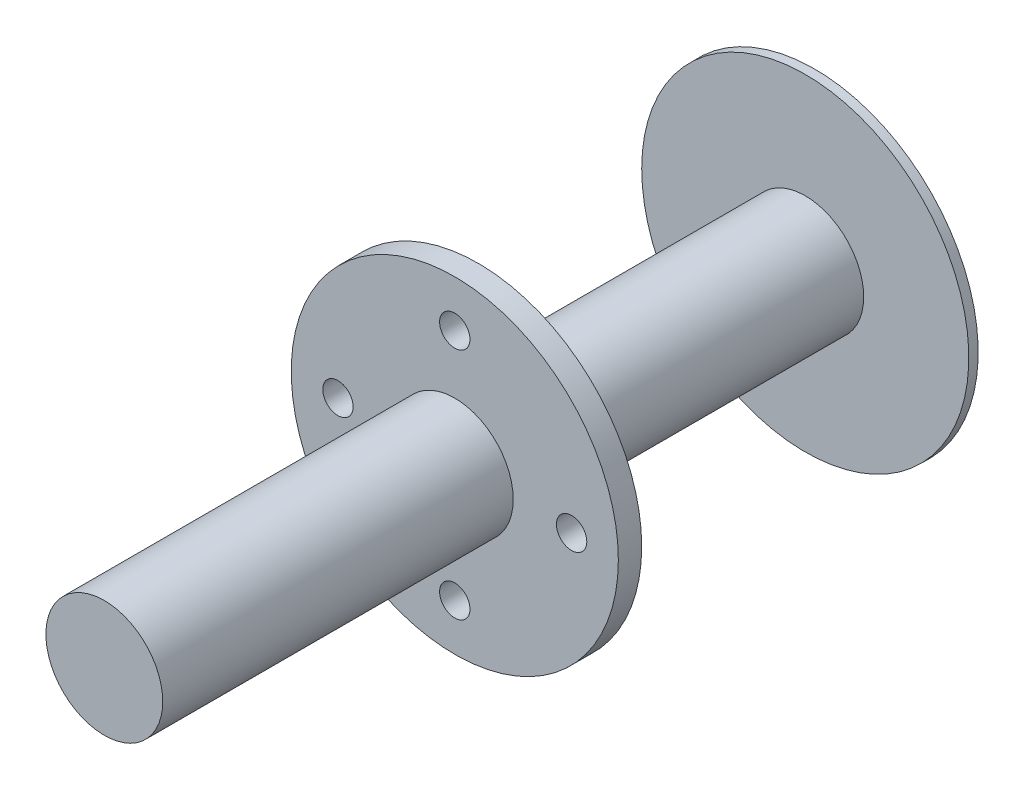
from build123d import *

# Parameters (mm, degrees)
SKETCH1_R                = 70
SKETCH1_R_2              = 6.5
BOSS_EXTRUDE1_DEPTH      = 10
SKETCH2_R                = 25
BOSS_EXTRUDE2_DEPTH      = 150
BOSS_EXTRUDE2_DEPTH_BACK = 150
SKETCH3_R                = 70
BOSS_EXTRUDE3_DEPTH      = 4


with BuildPart() as part:
    # Sketch1 → Boss-Extrude1 (new body)
    with BuildSketch(Plane.XY):
        Circle(SKETCH1_R)
        with Locations((0, 50)):
            Circle(SKETCH1_R_2, mode=Mode.SUBTRACT)
        with Locations((50, 0)):
            Circle(SKETCH1_R_2, mode=Mode.SUBTRACT)
        with Locations((0, -50)):
            Circle(SKETCH1_R_2, mode=Mode.SUBTRACT)
        with Locations((-50, 0)):
            Circle(SKETCH1_R_2, mode=Mode.SUBTRACT)
    extrude(amount=BOSS_EXTRUDE1_DEPTH)

    # Sketch2 → Boss-Extrude2 (add, two sides)
    with BuildSketch(Plane.XY.offset(10)) as boss_extrude2_sk:
        Circle(SKETCH2_R)
    extrude(amount=BOSS_EXTRUDE2_DEPTH)
    extrude(boss_extrude2_sk.sketch, amount=-BOSS_EXTRUDE2_DEPTH_BACK)

    # Sketch3 → Boss-Extrude3 (add)
    with BuildSketch(Plane(origin=(0, 0, -140), x_dir=(-1, 0, 0), z_dir=(0, 0, -1))):
        Circle(SKETCH3_R)
    extrude(amount=BOSS_EXTRUDE3_DEPTH)


solid = part.part
